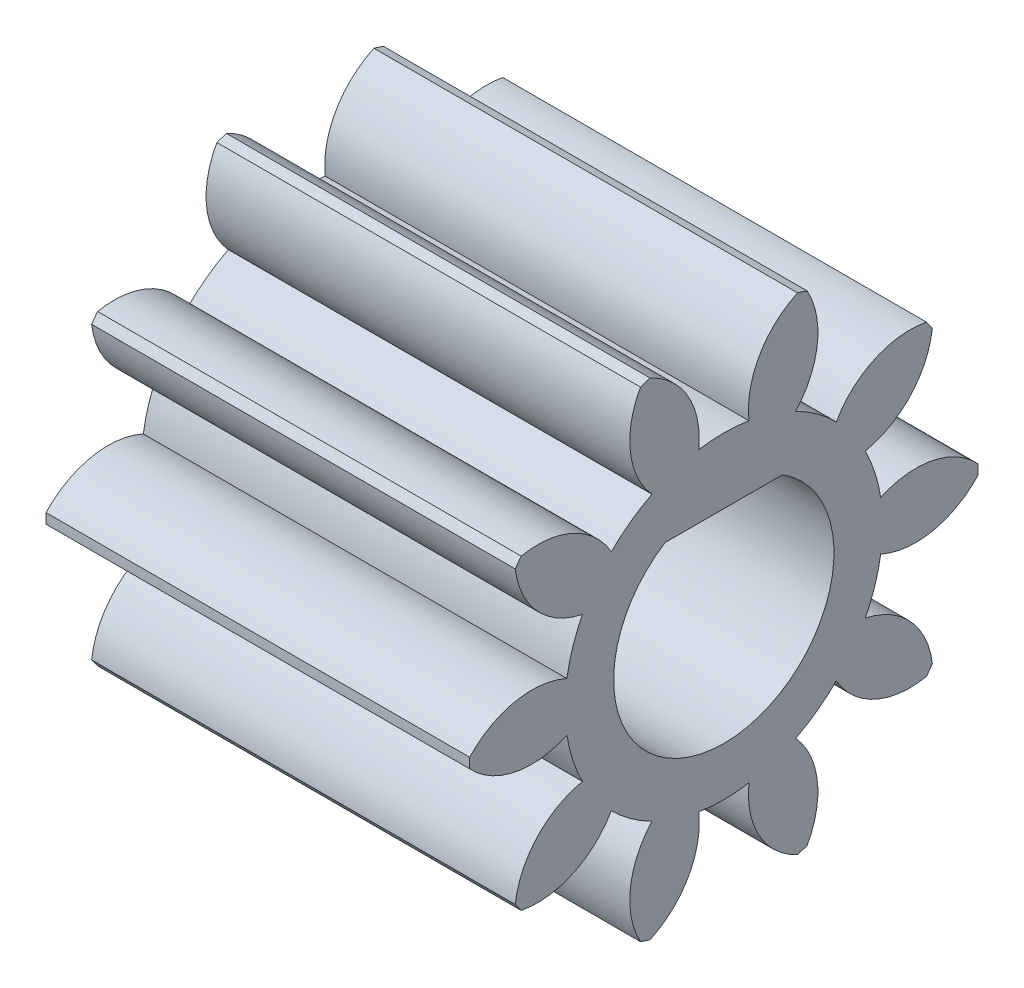
from build123d import *

# Parameters (mm, degrees)
BASPROSKE_W         = 10
BASPROSKE_H         = 6
TOOTHCUT_DEPTH      = 14.114877049
TEETHCUTS_COUNT     = 10
TEETHCUTS_ANGLE     = 324
BORSKE_R            = 2.5
BORE_DEPTH          = 50.0000508
SKETCH1_R           = 2.5
BOSS_EXTRUDE1_DEPTH = 10
CUT_EXTRUDE2_DEPTH  = 10
CUT_EXTRUDE4_DEPTH  = 12.8


with BuildPart() as part:
    # BasProSke → Base-Revolve (revolve)
    with BuildSketch(Plane(origin=(0, 0, 0), x_dir=(1, 0, 0), z_dir=(0, 1, 0)), mode=Mode.PRIVATE) as base_revolve_sk:
        with Locations((5, 3)):
            Rectangle(BASPROSKE_W, BASPROSKE_H)
    revolve(base_revolve_sk.sketch.rotate(Axis((-10, 0, 0), (1, 0, 0)), 180), axis=Axis((-10, 0, 0), (1, 0, 0)))

    # TooCutSke → ToothCut (cut, through all)
    with BuildSketch(Plane(origin=(0, 0, 0), x_dir=(0, 0, -1), z_dir=(1, 0, 0))):
        with BuildLine():
            ThreePointArc((0.59278292, 3.701838653), (0, 3.749), (-0.59278292, 3.701838653))
            ThreePointArc((-0.59278292, 3.701838653), (-0.846593509, 4.924114224), (-1.775771316, 5.757784417))
            ThreePointArc((-1.775771316, 5.757784417), (0, 6.0254), (1.775771316, 5.757784417))
            ThreePointArc((1.775771316, 5.757784417), (0.846593509, 4.924114224), (0.59278292, 3.701838653))
        make_face()
    toothcut = extrude(amount=TOOTHCUT_DEPTH, mode=Mode.SUBTRACT)

    # TeethCuts: ToothCut ×10 about axis
    teethcuts_axis = Axis((-10, 0, 0), (1, 0, 0))
    for i in range(1, TEETHCUTS_COUNT):
        add(toothcut.rotate(teethcuts_axis, i * TEETHCUTS_ANGLE / (TEETHCUTS_COUNT - 1)), mode=Mode.SUBTRACT)

    # BorSke → Bore (cut, symmetric)
    with BuildSketch(Plane(origin=(0, 0, 0), x_dir=(0, 0, -1), z_dir=(1, 0, 0))):
        with Locations(Location((0, 0, 0), (0, 0, 180))):
            Circle(BORSKE_R)
    extrude(amount=BORE_DEPTH, both=True, mode=Mode.SUBTRACT)

    # Sketch1 → Boss-Extrude1 (add)
    with BuildSketch(Plane(origin=(10, 0, 0), x_dir=(0, 0, -1), z_dir=(1, 0, 0))):
        Circle(SKETCH1_R)
    extrude(amount=-BOSS_EXTRUDE1_DEPTH)

    # Sketch2 → Cut-Extrude2 (cut)
    with BuildSketch(Plane.ZY):
        with BuildLine():
            Line((1.187434209, 2.2), (-1.187434209, 2.2))
            ThreePointArc((-1.187434209, 2.2), (-1.280900948, -2.146926352), (2.5, 0))
            ThreePointArc((2.5, 0), (2.146926352, 1.280900948), (1.187434209, 2.2))
        make_face()
    extrude(amount=-CUT_EXTRUDE2_DEPTH, mode=Mode.SUBTRACT)

    # Sketch3 → Cut-Extrude4 (cut)
    with BuildSketch(Plane.ZY):
        with BuildLine():
            ThreePointArc((-1.385640646, 2.2), (0, -2.6), (1.385640646, 2.2))
            Line((1.385640646, 2.2), (-1.385640646, 2.2))
        make_face()
    extrude(amount=-CUT_EXTRUDE4_DEPTH, mode=Mode.SUBTRACT)


solid = part.part
